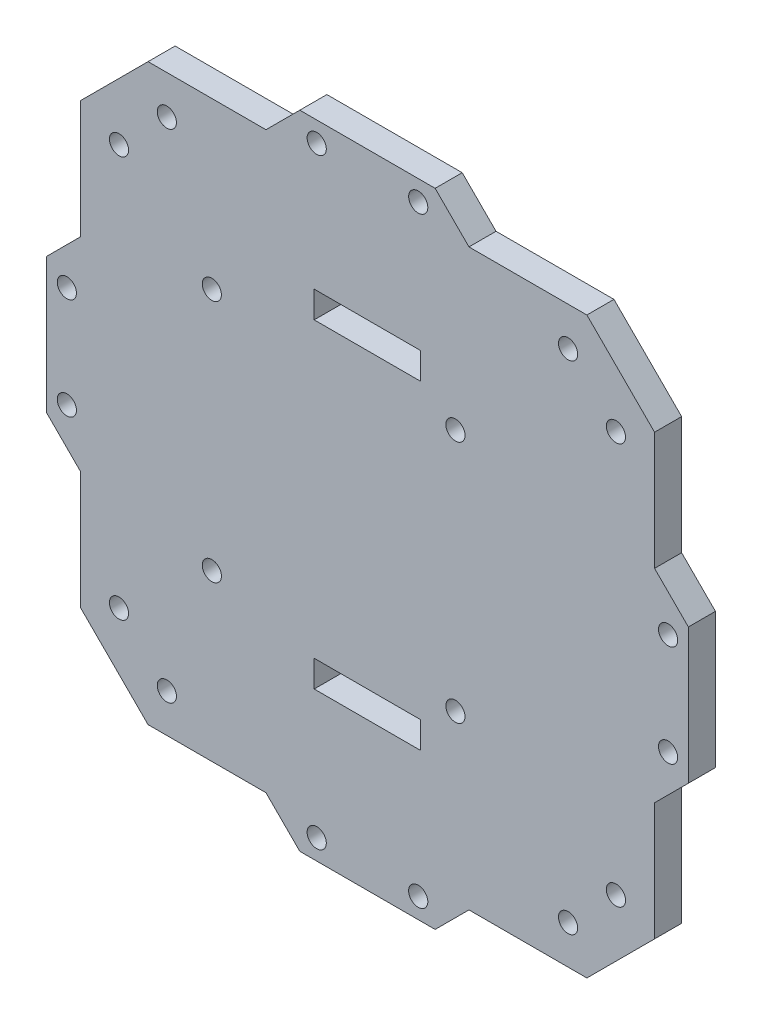
from build123d import *

# Parameters (mm, degrees)
SKETCH1_R           = 1.8
SKETCH1_W           = 5
SKETCH1_H           = 20
BOSS_EXTRUDE1_DEPTH = 5.08


with BuildPart() as part:
    # Sketch1 → Boss-Extrude1 (new body)
    with BuildSketch(Plane(origin=(0, 0, 0), x_dir=(0, 1, 0), z_dir=(0, 0, 1))):
        Polygon((-41.181536726, 53.881536726), (-19.05, 53.881536726), (-12.7, 60.231536726), (12.7, 60.231536726), (19.05, 53.881536726), (41.181536726, 53.881536726), (53.881536726, 41.181536726), (53.881536726, 19.05), (60.231536726, 12.7), (60.231536726, -12.7), (53.881536726, -19.05), (53.881536726, -41.181536726), (41.181536726, -53.881536726), (19.05, -53.881536726), (12.7, -60.231536726), (-12.7, -60.231536726), (-19.05, -53.881536726), (-41.181536726, -53.881536726), (-53.881536726, -41.181536726), (-53.881536726, -19.05), (-60.231536726, -12.7), (-60.231536726, 12.7), (-53.881536726, 19.05), (-53.881536726, 41.181536726), align=None)
        with Locations((-46.633511114, -37.653254993)):
            Circle(SKETCH1_R, mode=Mode.SUBTRACT)
        with Locations((-37.653254993, -46.633511114)):
            Circle(SKETCH1_R, mode=Mode.SUBTRACT)
        with Locations((46.633511114, -37.653254993)):
            Circle(SKETCH1_R, mode=Mode.SUBTRACT)
        with Locations((37.653254993, -46.633511114)):
            Circle(SKETCH1_R, mode=Mode.SUBTRACT)
        with Locations((-46.633511114, 37.653254993)):
            Circle(SKETCH1_R, mode=Mode.SUBTRACT)
        with Locations((-37.653254993, 46.633511114)):
            Circle(SKETCH1_R, mode=Mode.SUBTRACT)
        with Locations((37.653254993, 46.633511114)):
            Circle(SKETCH1_R, mode=Mode.SUBTRACT)
        with Locations((46.633511114, 37.653254993)):
            Circle(SKETCH1_R, mode=Mode.SUBTRACT)
        with Locations((-22.86, -16.51)):
            Circle(SKETCH1_R, mode=Mode.SUBTRACT)
        with Locations((22.86, -16.51)):
            Circle(SKETCH1_R, mode=Mode.SUBTRACT)
        with Locations((22.86, 29.21)):
            Circle(SKETCH1_R, mode=Mode.SUBTRACT)
        with Locations((-22.86, 29.21)):
            Circle(SKETCH1_R, mode=Mode.SUBTRACT)
        with Locations((9.525, -56.421536726)):
            Circle(SKETCH1_R, mode=Mode.SUBTRACT)
        with Locations((-9.525, -56.421536726)):
            Circle(SKETCH1_R, mode=Mode.SUBTRACT)
        with Locations((-56.421536726, -9.525)):
            Circle(SKETCH1_R, mode=Mode.SUBTRACT)
        with Locations((-56.421536726, 9.525)):
            Circle(SKETCH1_R, mode=Mode.SUBTRACT)
        with Locations((-9.525, 56.421536726)):
            Circle(SKETCH1_R, mode=Mode.SUBTRACT)
        with Locations((9.525, 56.421536726)):
            Circle(SKETCH1_R, mode=Mode.SUBTRACT)
        with Locations((56.421536726, 9.525)):
            Circle(SKETCH1_R, mode=Mode.SUBTRACT)
        with Locations((56.421536726, -9.525)):
            Circle(SKETCH1_R, mode=Mode.SUBTRACT)
        with Locations((-30, 0)):
            Rectangle(SKETCH1_W, SKETCH1_H, mode=Mode.SUBTRACT)
        with Locations((30, 0)):
            Rectangle(SKETCH1_W, SKETCH1_H, mode=Mode.SUBTRACT)
    extrude(amount=BOSS_EXTRUDE1_DEPTH)


solid = part.part
